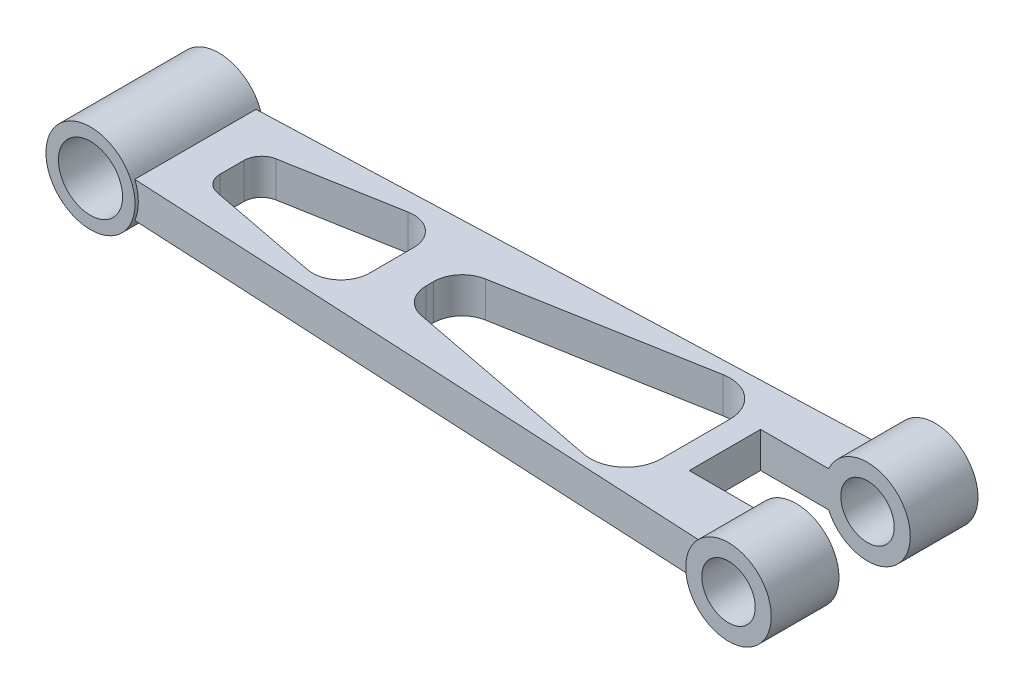
from build123d import *

# Parameters (mm, degrees)
SKETCH1_R           = 9
BOSS_EXTRUDE2_DEPTH = 18
SKETCH2_R           = 7.5
BOSS_EXTRUDE3_DEPTH = 29
BOSS_EXTRUDE5_DEPTH = 5
SKETCH7_R           = 12.5
BOSS_EXTRUDE6_DEPTH = 18
SKETCH8_R           = 12
BOSS_EXTRUDE7_DEPTH = 29
SKETCH9_R           = 9
SKETCH9_R_2         = 7.5
CUT_EXTRUDE1_DEPTH  = 29
SKETCH10_W          = 42
SKETCH10_H          = 20
CUT_EXTRUDE2_DEPTH  = 29
CUT_EXTRUDE3_DEPTH  = 29


with BuildPart() as part:
    # Sketch1 → Boss-Extrude2 (new body, symmetric)
    with BuildSketch(Plane.XY):
        with Locations((-95, 0)):
            Circle(SKETCH1_R)
    extrude(amount=BOSS_EXTRUDE2_DEPTH, both=True)



with BuildPart() as body_2:
    # Sketch2 → Boss-Extrude3 (new body, symmetric)
    with BuildSketch(Plane.XY):
        with Locations((95, 0)):
            Circle(SKETCH2_R)
    extrude(amount=BOSS_EXTRUDE3_DEPTH, both=True)


with BuildPart() as body_3:
    # Sketch5 → Boss-Extrude5 (new body, symmetric)
    with BuildSketch(Plane(origin=(0, 0, 0), x_dir=(1, 0, 0), z_dir=(0, 1, 0))):
        Polygon((-86, -16.9), (-86, 16.897851431), (87.5, 23.242786401), (87.5, -25.734348151), align=None)
    extrude(amount=BOSS_EXTRUDE5_DEPTH, both=True)


with BuildPart() as part_1:
    add(part.part)

    add(body_3.part)  # Boss-Extrude6 merges body 3
    # Sketch7 → Boss-Extrude6 (add, symmetric)
    with BuildSketch(Plane.XY):
        with Locations((-95, 0)):
            Circle(SKETCH7_R)
    extrude(amount=BOSS_EXTRUDE6_DEPTH, both=True)


    add(body_2.part)  # Boss-Extrude7 merges body 2
    # Sketch8 → Boss-Extrude7 (add, symmetric)
    with BuildSketch(Plane.XY):
        with Locations((95, 0)):
            Circle(SKETCH8_R)
    extrude(amount=BOSS_EXTRUDE7_DEPTH, both=True)

    # Sketch9 → Cut-Extrude1 (cut, symmetric)
    with BuildSketch(Plane.XY):
        with Locations((-95, 0)):
            Circle(SKETCH9_R)
        with Locations((95, 0)):
            Circle(SKETCH9_R_2)
    extrude(amount=CUT_EXTRUDE1_DEPTH, both=True, mode=Mode.SUBTRACT)

    # Sketch10 → Cut-Extrude2 (cut, symmetric)
    with BuildSketch(Plane(origin=(0, 5, 0), x_dir=(1, 0, 0), z_dir=(0, 1, 0))):
        with Locations((86, 0)):
            Rectangle(SKETCH10_W, SKETCH10_H)
    extrude(amount=CUT_EXTRUDE2_DEPTH, both=True, mode=Mode.SUBTRACT)

    # Sketch11 → Cut-Extrude3 (cut, symmetric)
    with BuildSketch(Plane(origin=(0, 5, 0), x_dir=(1, 0, 0), z_dir=(0, 1, 0))):
        with BuildLine():
            Line((-72.828382605, 2.841663292), (-72.828382605, -3.778949024))
            ThreePointArc((-72.828382605, -3.778949024), (-71.684142411, -6.96220464), (-68.775136079, -8.688496647))
            Line((-68.775136079, -8.688496647), (-37.343188163, -14.749809861))
            ThreePointArc((-37.343188163, -14.749809861), (-30.73517362, -13.063749355), (-27.828382605, -6.894533665))
            Line((-27.828382605, -6.894533665), (-27.828382605, 5.49132779))
            ThreePointArc((-27.828382605, 5.49132779), (-30.691131262, 11.623916855), (-37.230544764, 13.367490642))
            Line((-37.230544764, 13.367490642), (-68.704733954, 7.764265074))
            ThreePointArc((-68.704733954, 7.764265074), (-71.66125077, 6.052445381), (-72.828382605, 2.841663292))
        make_face()
        with BuildLine():
            Line((-16.777023504, 0.080024287), (-16.777023504, -2.052490903))
            ThreePointArc((-16.777023504, -2.052490903), (-14.946239194, -7.145699888), (-10.291829062, -9.907767099))
            Line((-10.291829062, -9.907767099), (46.329469548, -20.826575771))
            ThreePointArc((46.329469548, -20.826575771), (54.589487728, -18.719000138), (58.222976496, -11.007480526))
            Line((58.222976496, -11.007480526), (58.222976496, 8.196063057))
            ThreePointArc((58.222976496, 8.196063057), (54.644540675, 15.861799388), (46.470273797, 18.041266623))
            Line((46.470273797, 18.041266623), (-10.179185663, 7.956187139))
            ThreePointArc((-10.179185663, 7.956187139), (-14.909612569, 5.21727563), (-16.777023504, 0.080024287))
        make_face()
    extrude(amount=CUT_EXTRUDE3_DEPTH, both=True, mode=Mode.SUBTRACT)


solid = part_1.part
